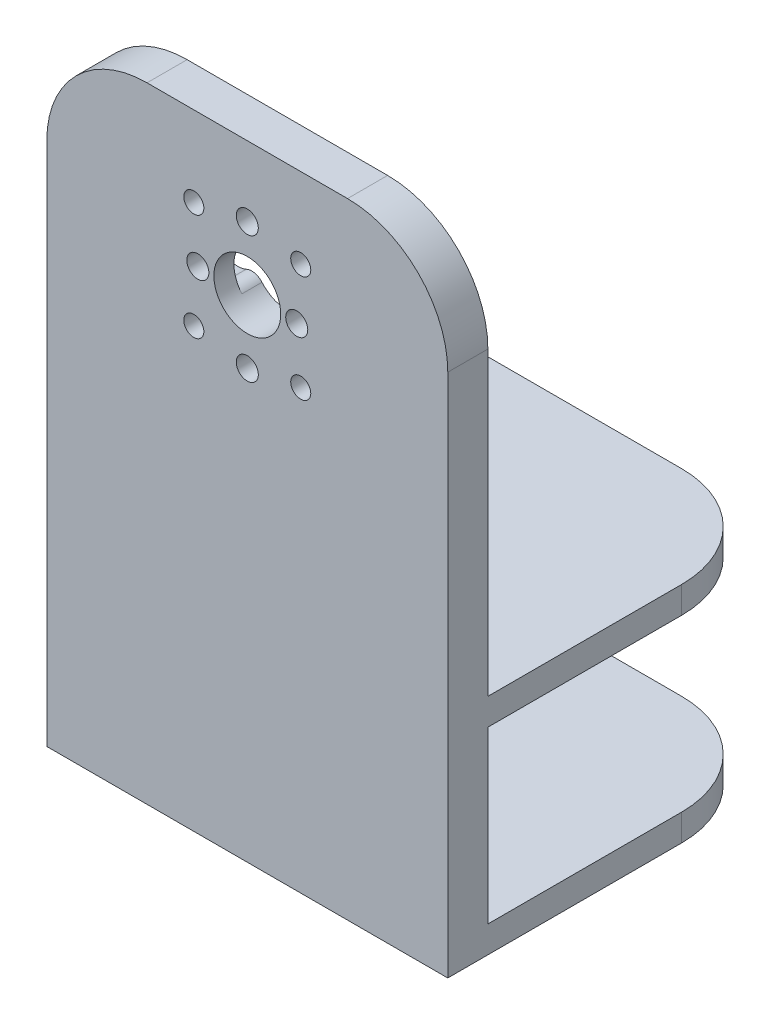
from build123d import *

# Parameters (mm, degrees)
SKETCH1_W           = 60
SKETCH1_H           = 60
SKETCH1_R           = 5
SKETCH1_R_2         = 1.65
SKETCH1_R_3         = 1.5
BOSS_EXTRUDE1_DEPTH = 6
SKETCH2_W           = 6
SKETCH2_H           = 25.5
BOSS_EXTRUDE2_DEPTH = 60
FILLET1_R           = 15
SKETCH3_R           = 3
CUT_EXTRUDE1_DEPTH  = 3
FILLET2_R           = 2


with BuildPart() as part:
    # Sketch1 → Boss-Extrude1 (new body)
    with BuildSketch(Plane.XY):
        with Locations((30, 30)):
            Rectangle(SKETCH1_W, SKETCH1_H)
        with Locations((30, 40)):
            Circle(SKETCH1_R, mode=Mode.SUBTRACT)
        with Locations((30, 49.5)):
            Circle(SKETCH1_R_2, mode=Mode.SUBTRACT)
        with Locations((30, 30.5)):
            Circle(SKETCH1_R_2, mode=Mode.SUBTRACT)
        with Locations((22.6, 40)):
            Circle(SKETCH1_R_2, mode=Mode.SUBTRACT)
        with Locations((37.4, 40)):
            Circle(SKETCH1_R_2, mode=Mode.SUBTRACT)
        with Locations((22, 48)):
            Circle(SKETCH1_R_3, mode=Mode.SUBTRACT)
        with Locations((38, 48)):
            Circle(SKETCH1_R_3, mode=Mode.SUBTRACT)
        with Locations((38, 32)):
            Circle(SKETCH1_R_3, mode=Mode.SUBTRACT)
        with Locations((22, 32)):
            Circle(SKETCH1_R_3, mode=Mode.SUBTRACT)
    extrude(amount=BOSS_EXTRUDE1_DEPTH)

    # Sketch2 → Boss-Extrude2 (add)
    with BuildSketch(Plane(origin=(60, 0, 0), x_dir=(0, 0, -1), z_dir=(1, 0, 0))):
        Polygon((44, 0), (-6, 0), (-6, -4), (0, -4), (44, -4), align=None)
        with Locations((-3, -16.75)):
            Rectangle(SKETCH2_W, SKETCH2_H)
        Polygon((0, -29.5), (-6, -29.5), (-6, -33.5), (44, -33.5), (44, -29.5), align=None)
    extrude(amount=-BOSS_EXTRUDE2_DEPTH)

    # Fillet1
    fillet1_edges = [part.edges().sort_by_distance(p)[0] for p in [
        (60, -2, -44),
        (0, -31.5, -44),
        (0, -2, -44),
        (60, -31.5, -44),
        (0, 60, 3),
        (60, 60, 3),
    ]]
    fillet(fillet1_edges, radius=FILLET1_R)

    # Sketch3 → Cut-Extrude1 (cut)
    with BuildSketch(Plane(origin=(0, 0, 0), x_dir=(-1, 0, 0), z_dir=(0, 0, -1))):
        with Locations((-30, 49.5)):
            Circle(SKETCH3_R)
        with Locations((-22.6, 40)):
            Circle(SKETCH3_R)
        with Locations((-30, 30.5)):
            Circle(SKETCH3_R)
        with Locations((-37.4, 40)):
            Circle(SKETCH3_R)
    extrude(amount=-CUT_EXTRUDE1_DEPTH, mode=Mode.SUBTRACT)

    # Fillet2
    fillet2_edges = [part.edges().sort_by_distance(p)[0] for p in [
        (34.781081081, 41.463305743, 1.5),
        (34.781081081, 38.536694257, 1.5),
        (25.218918919, 38.536694257, 1.5),
        (25.218918919, 41.463305743, 1.5),
    ]]
    fillet(fillet2_edges, radius=FILLET2_R)


solid = part.part
